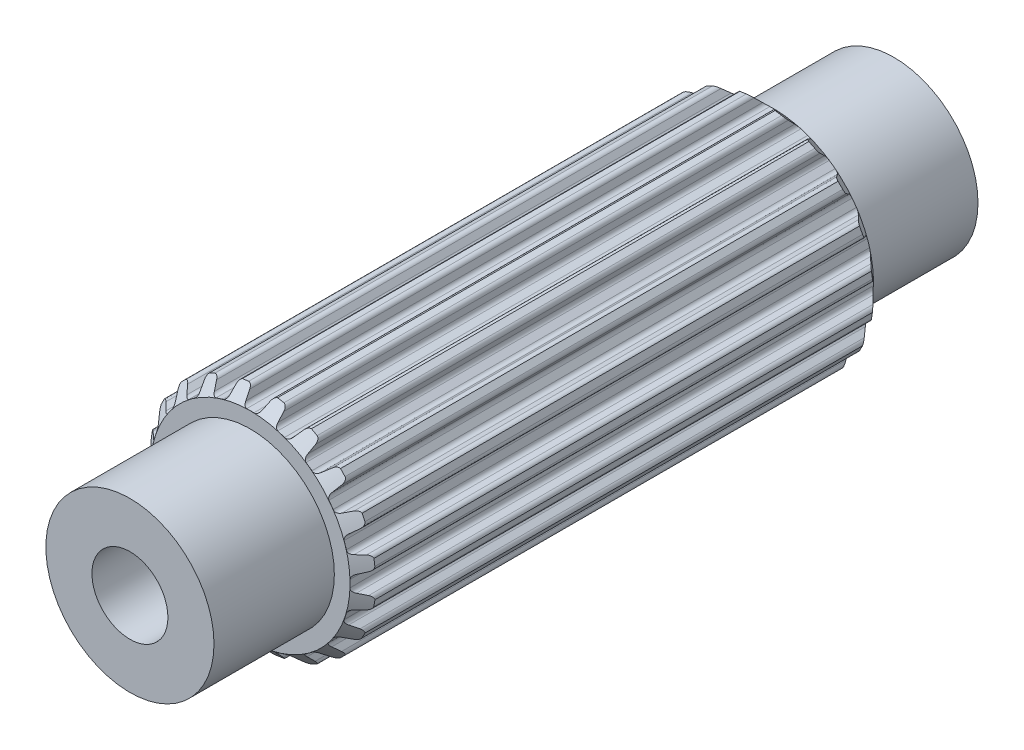
from build123d import *

# Parameters (mm, degrees)
BOSS_EXTRUDE1_DEPTH            = 7.7851
SKETCH2_R                      = 2.5019
BOSS_EXTRUDE2_DEPTH            = 11.3665
CUT_EXTRUDE1_REACH             = 13.367
SKETCH6_R                      = 1.1303
CUT_EXTRUDE1_DIRECTION_2_REACH = 13.367
SKETCH7_R                      = 1.1303
BOSS_EXTRUDE3_DEPTH            = 1.8415
BOSS_EXTRUDE3_DEPTH_BACK       = 1.8415


with BuildPart() as part:
    # Sketch1 → Boss-Extrude1 (new body, symmetric)
    with BuildSketch(Plane.XY):
        with BuildLine():
            Line((-0.106949245, 2.969874934), (0.106949245, 2.969874934))
            ThreePointArc((0.106949245, 2.969874934), (0.196343213, 2.986924176), (0.253739238, 3.057547504))
            Line((0.253739238, 3.057547504), (0.315888147, 3.237526941))
            ThreePointArc((0.315888147, 3.237526941), (0.359032156, 3.298322911), (0.4281449, 3.326269005))
            Line((0.4281449, 3.326269005), (0.620027588, 3.2937547))
            ThreePointArc((0.620027588, 3.2937547), (0.689621142, 3.24802576), (0.718272212, 3.169836791))
            Line((0.718272212, 3.169836791), (0.724389167, 2.979527391))
            ThreePointArc((0.724389167, 2.979527391), (0.750934762, 2.9040661), (0.816027049, 2.857568043))
            Line((0.816027049, 2.857568043), (1.019456602, 2.791469774))
            ThreePointArc((1.019456602, 2.791469774), (1.109743823, 2.780060312), (1.186154496, 2.829490741))
            Line((1.186154496, 2.829490741), (1.300878326, 2.981456288))
            ThreePointArc((1.300878326, 2.981456288), (1.360697704, 3.02594446), (1.435063648, 3.031165762))
            Line((1.435063648, 3.031165762), (1.607507455, 2.940947809))
            ThreePointArc((1.607507455, 2.940947809), (1.659563839, 2.875951412), (1.662650905, 2.792735615))
            Line((1.662650905, 2.792735615), (1.609659636, 2.609850378))
            ThreePointArc((1.609659636, 2.609850378), (1.611587176, 2.529879385), (1.659124931, 2.465542482))
            Line((1.659124931, 2.465542482), (1.832172444, 2.339816104))
            ThreePointArc((1.832172444, 2.339816104), (1.914514976, 2.301064775), (2.002460687, 2.32446371))
            Line((2.002460687, 2.32446371), (2.158529469, 2.433539921))
            ThreePointArc((2.158529469, 2.433539921), (2.229168681, 2.457365482), (2.301508367, 2.439350895))
            Line((2.301508367, 2.439350895), (2.437633293, 2.300260456))
            ThreePointArc((2.437633293, 2.300260456), (2.467056864, 2.222358901), (2.444277744, 2.14226202))
            Line((2.444277744, 2.14226202), (2.337365406, 1.984703026))
            ThreePointArc((2.337365406, 1.984703026), (2.314486209, 1.908050449), (2.339816104, 1.832172444))
            Line((2.339816104, 1.832172444), (2.465542482, 1.659124931))
            ThreePointArc((2.465542482, 1.659124931), (2.531880064, 1.596824985), (2.622752074, 1.591901975))
            Line((2.622752074, 1.591901975), (2.804888709, 1.64741171))
            ThreePointArc((2.804888709, 1.64741171), (2.879433095, 1.648242449), (2.942665411, 1.608755366))
            Line((2.942665411, 1.608755366), (3.0291466, 1.434407582))
            ThreePointArc((3.0291466, 1.434407582), (3.033057175, 1.351226417), (2.986641646, 1.282088892))
            Line((2.986641646, 1.282088892), (2.836273564, 1.165279113))
            ThreePointArc((2.836273564, 1.165279113), (2.790827206, 1.099448241), (2.791469774, 1.019456602))
            Line((2.791469774, 1.019456602), (2.857568043, 0.816027049))
            ThreePointArc((2.857568043, 0.816027049), (2.901407091, 0.736276839), (2.986310214, 0.703513784))
            Line((2.986310214, 0.703513784), (3.1766859, 0.700023363))
            ThreePointArc((3.1766859, 0.700023363), (3.247838536, 0.677777961), (3.295773863, 0.620683653))
            Line((3.295773863, 0.620683653), (3.324145932, 0.4281449))
            ThreePointArc((3.324145932, 0.4281449), (3.302160717, 0.347826477), (3.236652255, 0.29641597))
            Line((3.236652255, 0.29641597), (3.057547504, 0.231789562))
            ThreePointArc((3.057547504, 0.231789562), (2.993982591, 0.183224379), (2.969874934, 0.106949245))
            Line((2.969874934, 0.106949245), (2.969874934, -0.106949245))
            ThreePointArc((2.969874934, -0.106949245), (2.986924176, -0.196343213), (3.057547504, -0.253739238))
            Line((3.057547504, -0.253739238), (3.237526941, -0.315888147))
            ThreePointArc((3.237526941, -0.315888147), (3.298322911, -0.359032156), (3.326269005, -0.4281449))
            Line((3.326269005, -0.4281449), (3.2937547, -0.620027588))
            ThreePointArc((3.2937547, -0.620027588), (3.24802576, -0.689621142), (3.169836791, -0.718272212))
            Line((3.169836791, -0.718272212), (2.979527391, -0.724389167))
            ThreePointArc((2.979527391, -0.724389167), (2.9040661, -0.750934762), (2.857568043, -0.816027049))
            Line((2.857568043, -0.816027049), (2.791469774, -1.019456602))
            ThreePointArc((2.791469774, -1.019456602), (2.780060312, -1.109743823), (2.829490741, -1.186154496))
            Line((2.829490741, -1.186154496), (2.981456288, -1.300878326))
            ThreePointArc((2.981456288, -1.300878326), (3.02594446, -1.360697704), (3.031165762, -1.435063648))
            Line((3.031165762, -1.435063648), (2.940947809, -1.607507455))
            ThreePointArc((2.940947809, -1.607507455), (2.875951412, -1.659563839), (2.792735615, -1.662650905))
            Line((2.792735615, -1.662650905), (2.609850378, -1.609659636))
            ThreePointArc((2.609850378, -1.609659636), (2.529879385, -1.611587176), (2.465542482, -1.659124931))
            Line((2.465542482, -1.659124931), (2.339816104, -1.832172444))
            ThreePointArc((2.339816104, -1.832172444), (2.301064775, -1.914514976), (2.32446371, -2.002460687))
            Line((2.32446371, -2.002460687), (2.433539921, -2.158529469))
            ThreePointArc((2.433539921, -2.158529469), (2.457365482, -2.229168681), (2.439350895, -2.301508367))
            Line((2.439350895, -2.301508367), (2.300260456, -2.437633293))
            ThreePointArc((2.300260456, -2.437633293), (2.222358901, -2.467056864), (2.14226202, -2.444277744))
            Line((2.14226202, -2.444277744), (1.984703026, -2.337365406))
            ThreePointArc((1.984703026, -2.337365406), (1.908050449, -2.314486209), (1.832172444, -2.339816104))
            Line((1.832172444, -2.339816104), (1.659124931, -2.465542482))
            ThreePointArc((1.659124931, -2.465542482), (1.596824985, -2.531880064), (1.591901975, -2.622752074))
            Line((1.591901975, -2.622752074), (1.64741171, -2.804888709))
            ThreePointArc((1.64741171, -2.804888709), (1.648242449, -2.879433095), (1.608755366, -2.942665411))
            Line((1.608755366, -2.942665411), (1.434407582, -3.0291466))
            ThreePointArc((1.434407582, -3.0291466), (1.351226417, -3.033057175), (1.282088892, -2.986641646))
            Line((1.282088892, -2.986641646), (1.165279113, -2.836273564))
            ThreePointArc((1.165279113, -2.836273564), (1.099448241, -2.790827206), (1.019456602, -2.791469774))
            Line((1.019456602, -2.791469774), (0.816027049, -2.857568043))
            ThreePointArc((0.816027049, -2.857568043), (0.736276839, -2.901407091), (0.703513784, -2.986310214))
            Line((0.703513784, -2.986310214), (0.700023363, -3.1766859))
            ThreePointArc((0.700023363, -3.1766859), (0.677777961, -3.247838536), (0.620683653, -3.295773863))
            Line((0.620683653, -3.295773863), (0.4281449, -3.324145932))
            ThreePointArc((0.4281449, -3.324145932), (0.347826477, -3.302160717), (0.29641597, -3.236652255))
            Line((0.29641597, -3.236652255), (0.231789562, -3.057547504))
            ThreePointArc((0.231789562, -3.057547504), (0.183224379, -2.993982591), (0.106949245, -2.969874934))
            Line((0.106949245, -2.969874934), (-0.106949245, -2.969874934))
            ThreePointArc((-0.106949245, -2.969874934), (-0.196343213, -2.986924176), (-0.253739238, -3.057547504))
            Line((-0.253739238, -3.057547504), (-0.315888147, -3.237526941))
            ThreePointArc((-0.315888147, -3.237526941), (-0.359032156, -3.298322911), (-0.4281449, -3.326269005))
            Line((-0.4281449, -3.326269005), (-0.620027588, -3.2937547))
            ThreePointArc((-0.620027588, -3.2937547), (-0.689621142, -3.24802576), (-0.718272212, -3.169836791))
            Line((-0.718272212, -3.169836791), (-0.724389167, -2.979527391))
            ThreePointArc((-0.724389167, -2.979527391), (-0.750934762, -2.9040661), (-0.816027049, -2.857568043))
            Line((-0.816027049, -2.857568043), (-1.019456602, -2.791469774))
            ThreePointArc((-1.019456602, -2.791469774), (-1.109743823, -2.780060312), (-1.186154496, -2.829490741))
            Line((-1.186154496, -2.829490741), (-1.300878326, -2.981456288))
            ThreePointArc((-1.300878326, -2.981456288), (-1.360697704, -3.02594446), (-1.435063648, -3.031165762))
            Line((-1.435063648, -3.031165762), (-1.607507455, -2.940947809))
            ThreePointArc((-1.607507455, -2.940947809), (-1.659563839, -2.875951412), (-1.662650905, -2.792735615))
            Line((-1.662650905, -2.792735615), (-1.609659636, -2.609850378))
            ThreePointArc((-1.609659636, -2.609850378), (-1.611587176, -2.529879385), (-1.659124931, -2.465542482))
            Line((-1.659124931, -2.465542482), (-1.832172444, -2.339816104))
            ThreePointArc((-1.832172444, -2.339816104), (-1.914514976, -2.301064775), (-2.002460687, -2.32446371))
            Line((-2.002460687, -2.32446371), (-2.158529469, -2.433539921))
            ThreePointArc((-2.158529469, -2.433539921), (-2.229168681, -2.457365482), (-2.301508367, -2.439350895))
            Line((-2.301508367, -2.439350895), (-2.437633293, -2.300260456))
            ThreePointArc((-2.437633293, -2.300260456), (-2.467056864, -2.222358901), (-2.444277744, -2.14226202))
            Line((-2.444277744, -2.14226202), (-2.337365406, -1.984703026))
            ThreePointArc((-2.337365406, -1.984703026), (-2.314486209, -1.908050449), (-2.339816104, -1.832172444))
            Line((-2.339816104, -1.832172444), (-2.465542482, -1.659124931))
            ThreePointArc((-2.465542482, -1.659124931), (-2.531880064, -1.596824985), (-2.622752074, -1.591901975))
            Line((-2.622752074, -1.591901975), (-2.804888709, -1.64741171))
            ThreePointArc((-2.804888709, -1.64741171), (-2.879433095, -1.648242449), (-2.942665411, -1.608755366))
            Line((-2.942665411, -1.608755366), (-3.0291466, -1.434407582))
            ThreePointArc((-3.0291466, -1.434407582), (-3.033057175, -1.351226417), (-2.986641646, -1.282088892))
            Line((-2.986641646, -1.282088892), (-2.836273564, -1.165279113))
            ThreePointArc((-2.836273564, -1.165279113), (-2.790827206, -1.099448241), (-2.791469774, -1.019456602))
            Line((-2.791469774, -1.019456602), (-2.857568043, -0.816027049))
            ThreePointArc((-2.857568043, -0.816027049), (-2.901407091, -0.736276839), (-2.986310214, -0.703513784))
            Line((-2.986310214, -0.703513784), (-3.1766859, -0.700023363))
            ThreePointArc((-3.1766859, -0.700023363), (-3.247838536, -0.677777961), (-3.295773863, -0.620683653))
            Line((-3.295773863, -0.620683653), (-3.324145932, -0.4281449))
            ThreePointArc((-3.324145932, -0.4281449), (-3.302160717, -0.347826477), (-3.236652255, -0.29641597))
            Line((-3.236652255, -0.29641597), (-3.057547504, -0.231789562))
            ThreePointArc((-3.057547504, -0.231789562), (-2.993982591, -0.183224379), (-2.969874934, -0.106949245))
            Line((-2.969874934, -0.106949245), (-2.969874934, 0.106949245))
            ThreePointArc((-2.969874934, 0.106949245), (-2.986924176, 0.196343213), (-3.057547504, 0.253739238))
            Line((-3.057547504, 0.253739238), (-3.237526941, 0.315888147))
            ThreePointArc((-3.237526941, 0.315888147), (-3.298322911, 0.359032156), (-3.326269005, 0.4281449))
            Line((-3.326269005, 0.4281449), (-3.2937547, 0.620027588))
            ThreePointArc((-3.2937547, 0.620027588), (-3.24802576, 0.689621142), (-3.169836791, 0.718272212))
            Line((-3.169836791, 0.718272212), (-2.979527391, 0.724389167))
            ThreePointArc((-2.979527391, 0.724389167), (-2.9040661, 0.750934762), (-2.857568043, 0.816027049))
            Line((-2.857568043, 0.816027049), (-2.791469774, 1.019456602))
            ThreePointArc((-2.791469774, 1.019456602), (-2.780060312, 1.109743823), (-2.829490741, 1.186154496))
            Line((-2.829490741, 1.186154496), (-2.981456288, 1.300878326))
            ThreePointArc((-2.981456288, 1.300878326), (-3.02594446, 1.360697704), (-3.031165762, 1.435063648))
            Line((-3.031165762, 1.435063648), (-2.940947809, 1.607507455))
            ThreePointArc((-2.940947809, 1.607507455), (-2.875951412, 1.659563839), (-2.792735615, 1.662650905))
            Line((-2.792735615, 1.662650905), (-2.609850378, 1.609659636))
            ThreePointArc((-2.609850378, 1.609659636), (-2.529879385, 1.611587176), (-2.465542482, 1.659124931))
            Line((-2.465542482, 1.659124931), (-2.339816104, 1.832172444))
            ThreePointArc((-2.339816104, 1.832172444), (-2.301064775, 1.914514976), (-2.32446371, 2.002460687))
            Line((-2.32446371, 2.002460687), (-2.433539921, 2.158529469))
            ThreePointArc((-2.433539921, 2.158529469), (-2.457365482, 2.229168681), (-2.439350895, 2.301508367))
            Line((-2.439350895, 2.301508367), (-2.300260456, 2.437633293))
            ThreePointArc((-2.300260456, 2.437633293), (-2.222358901, 2.467056864), (-2.14226202, 2.444277744))
            Line((-2.14226202, 2.444277744), (-1.984703026, 2.337365406))
            ThreePointArc((-1.984703026, 2.337365406), (-1.908050449, 2.314486209), (-1.832172444, 2.339816104))
            Line((-1.832172444, 2.339816104), (-1.659124931, 2.465542482))
            ThreePointArc((-1.659124931, 2.465542482), (-1.596824985, 2.531880064), (-1.591901975, 2.622752074))
            Line((-1.591901975, 2.622752074), (-1.64741171, 2.804888709))
            ThreePointArc((-1.64741171, 2.804888709), (-1.648242449, 2.879433095), (-1.608755366, 2.942665411))
            Line((-1.608755366, 2.942665411), (-1.434407582, 3.0291466))
            ThreePointArc((-1.434407582, 3.0291466), (-1.351226417, 3.033057175), (-1.282088892, 2.986641646))
            Line((-1.282088892, 2.986641646), (-1.165279113, 2.836273564))
            ThreePointArc((-1.165279113, 2.836273564), (-1.099448241, 2.790827206), (-1.019456602, 2.791469774))
            Line((-1.019456602, 2.791469774), (-0.816027049, 2.857568043))
            ThreePointArc((-0.816027049, 2.857568043), (-0.736276839, 2.901407091), (-0.703513784, 2.986310214))
            Line((-0.703513784, 2.986310214), (-0.700023363, 3.1766859))
            ThreePointArc((-0.700023363, 3.1766859), (-0.677777961, 3.247838536), (-0.620683653, 3.295773863))
            Line((-0.620683653, 3.295773863), (-0.4281449, 3.324145932))
            ThreePointArc((-0.4281449, 3.324145932), (-0.347826477, 3.302160717), (-0.29641597, 3.236652255))
            Line((-0.29641597, 3.236652255), (-0.231789562, 3.057547504))
            ThreePointArc((-0.231789562, 3.057547504), (-0.183224379, 2.993982591), (-0.106949245, 2.969874934))
        make_face()
    extrude(amount=BOSS_EXTRUDE1_DEPTH, both=True)

    # Sketch2 → Boss-Extrude2 (add, symmetric)
    with BuildSketch(Plane.XY):
        Circle(SKETCH2_R)
    extrude(amount=BOSS_EXTRUDE2_DEPTH, both=True)

    # Sketch3 → Cut-Revolve1 (revolve, cut)
    with BuildSketch(Plane(origin=(0, 0, 0), x_dir=(0, 0, -1), z_dir=(1, 0, 0))):
        Polygon((-6.653875505, 4.101099429), (-7.7851, 2.969874934), (-7.7851, 4.101099429), align=None)
        Polygon((7.7851, 4.498969155), (7.7851, 2.969874934), (7.020552889, 3.734422045), align=None)
    revolve(axis=Axis((0, 0, 14.360793934), (0, 0, -1)), mode=Mode.SUBTRACT)

    # Cut-Extrude1: up to this face of the body (flat: up to its plane)
    cut_extrude1_end = Plane(part.part.faces().sort_by_distance((0, 0, -11.3665))[0])
    # Sketch6 → Cut-Extrude1 (cut, up to the picked face)
    with BuildSketch(Plane.XY, mode=Mode.PRIVATE) as cut_extrude1_sk1:
        Circle(SKETCH6_R)
    cut_extrude1_tool1 = split(extrude(cut_extrude1_sk1.sketch, amount=-CUT_EXTRUDE1_REACH, mode=Mode.PRIVATE), bisect_by=cut_extrude1_end, keep=Keep.BOTH, mode=Mode.PRIVATE)
    add(cut_extrude1_tool1.solids().sort_by_distance((0, 0, 0))[0], mode=Mode.SUBTRACT)

    # Cut-Extrude1 direction 2: up to this face of the body (flat: up to its plane)
    cut_extrude1_direction_2_end = Plane(part.part.faces().sort_by_distance((0, 0, 11.3665))[0])
    # Sketch6 → Cut-Extrude1 direction 2 (cut, up to the picked face)
    with BuildSketch(Plane.XY, mode=Mode.PRIVATE) as cut_extrude1_direction_2_sk1:
        Circle(SKETCH6_R)
    cut_extrude1_direction_2_tool1 = split(extrude(cut_extrude1_direction_2_sk1.sketch, amount=CUT_EXTRUDE1_DIRECTION_2_REACH, mode=Mode.PRIVATE), bisect_by=cut_extrude1_direction_2_end, keep=Keep.BOTH, mode=Mode.PRIVATE)
    add(cut_extrude1_direction_2_tool1.solids().sort_by_distance((0, 0, 0))[0], mode=Mode.SUBTRACT)

    # Sketch7 → Boss-Extrude3 (add, two sides)
    with BuildSketch(Plane.XY) as boss_extrude3_sk:
        Circle(SKETCH7_R)
    extrude(amount=BOSS_EXTRUDE3_DEPTH)
    extrude(boss_extrude3_sk.sketch, amount=-BOSS_EXTRUDE3_DEPTH_BACK)


solid = part.part
